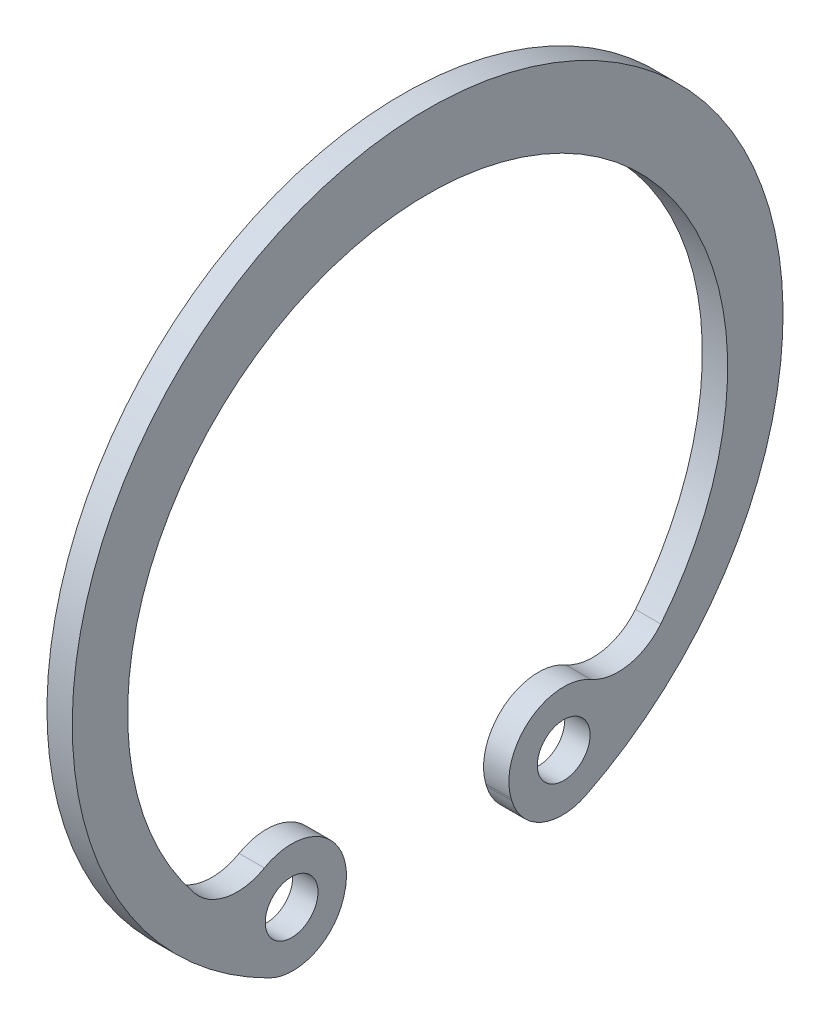
from build123d import *

# Parameters (mm, degrees)
EXTRUDE_1_DEPTH      = 0.6
EXTRUDE_1_DEPTH_BACK = 0.6
SKETCH_1_R           = 1.25


with BuildPart() as part:
    # ｽｹｯﾁ1 → ﾎﾞｽ - 押し出し1 (new, two sides: drawn at the far end of the back side and taken through both)
    with BuildSketch(Plane(origin=(0, 0, 0), x_dir=(0, 0, -1), z_dir=(1, 0, 0)).offset(-EXTRUDE_1_DEPTH_BACK)):
        with BuildLine():
            Line((-3.989591726, -13.555650403), (-3.955781017, -13.440769939))
            ThreePointArc((-3.955781017, -13.440769939), (-4.838154074, -10.666604704), (-7.741194161, -10.449963955))
            ThreePointArc((-7.741194161, -10.449963955), (-9.510855368, -10.748832352), (-11.052535247, -9.830003608))
            ThreePointArc((-11.052535247, -9.830003608), (-1.19e-07, 13.35), (11.052535397, -9.830003423))
            ThreePointArc((11.052535397, -9.830003423), (9.510855453, -10.748832336), (7.741194103, -10.449963921))
            ThreePointArc((7.741194103, -10.449963921), (4.838154048, -10.666604724), (3.955781017, -13.440769939))
            Line((3.955781017, -13.440769939), (3.989591726, -13.555650403))
            ThreePointArc((3.989591726, -13.555650403), (5.387658916, -15.140997106), (7.500750152, -15.088447473))
            ThreePointArc((7.500750152, -15.088447473), (0, 16.85), (-7.500750152, -15.088447473))
            ThreePointArc((-7.500750152, -15.088447473), (-5.387658916, -15.140997106), (-3.989591726, -13.555650403))
        make_face()
        with Locations((6.45, -12.706691151)):
            Circle(SKETCH_1_R, mode=Mode.SUBTRACT)
        with Locations((-6.45, -12.706691151)):
            Circle(SKETCH_1_R, mode=Mode.SUBTRACT)
    extrude(amount=EXTRUDE_1_DEPTH + EXTRUDE_1_DEPTH_BACK)


solid = part.part
